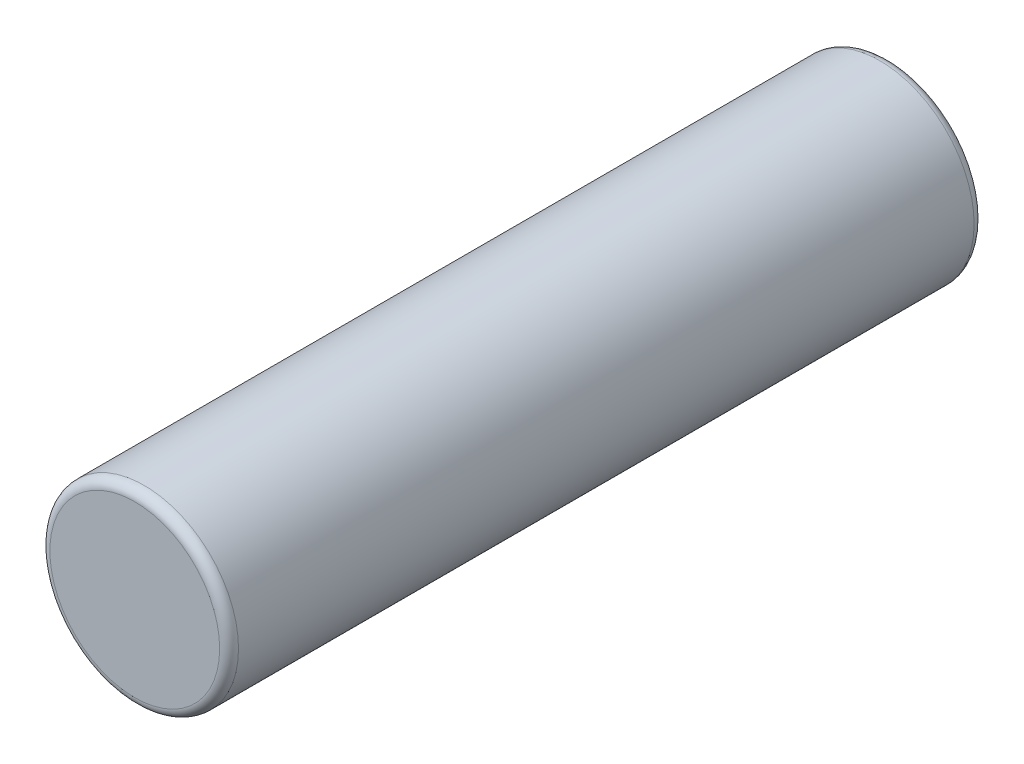
from build123d import *

# Parameters (mm, degrees)
SKETCH1_R           = 1.27
BOSS_EXTRUDE1_DEPTH = 10.16
FILLET1_R           = 0.127
FILLET2_R           = 0.127


with BuildPart() as part:
    # Sketch1 → Boss-Extrude1 (new body)
    with BuildSketch(Plane.XY):
        Circle(SKETCH1_R)
    extrude(amount=BOSS_EXTRUDE1_DEPTH)

    # Fillet1
    fillet1_edges = [part.edges().sort_by_distance(p)[0] for p in [
        (-1.27, 0, 10.16),
    ]]
    fillet(fillet1_edges, radius=FILLET1_R)

    # Fillet2
    fillet2_edges = [part.edges().sort_by_distance(p)[0] for p in [
        (-1.27, 0, 0),
    ]]
    fillet(fillet2_edges, radius=FILLET2_R)


solid = part.part
